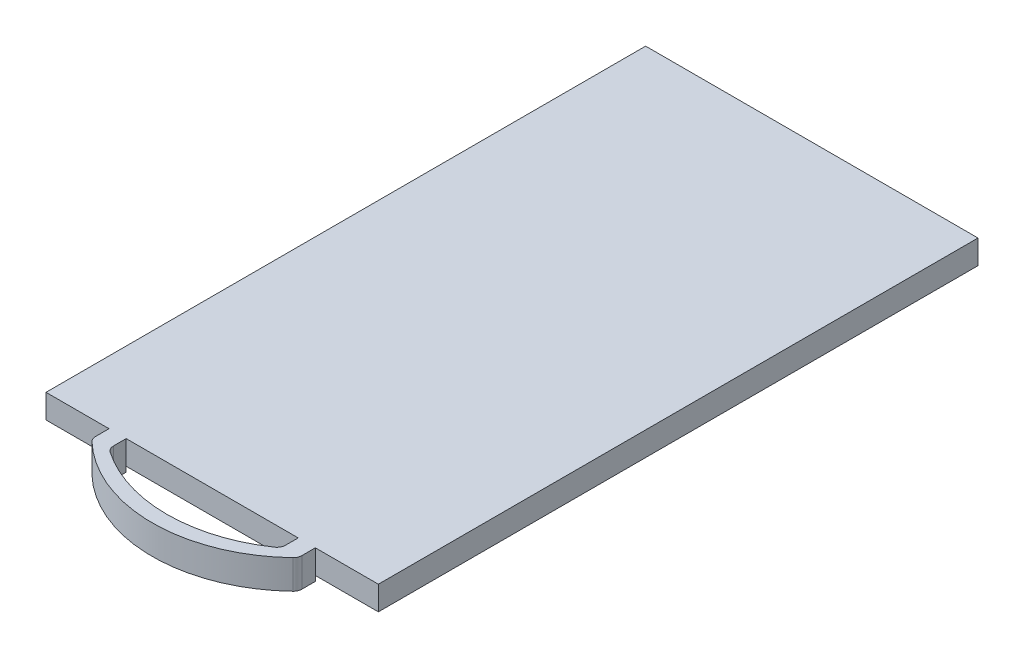
from build123d import *

# Parameters (mm, degrees)
SKETCH1_W           = 19.4
SKETCH1_H           = 1.4
BOSS_EXTRUDE1_DEPTH = 35
BOSS_EXTRUDE2_DEPTH = 1.7


with BuildPart() as part:
    # Sketch1 → Boss-Extrude1 (new body)
    with BuildSketch(Plane.XY):
        with Locations((9.7, 0.7)):
            Rectangle(SKETCH1_W, SKETCH1_H)
    extrude(amount=BOSS_EXTRUDE1_DEPTH)

    # Sketch3 → Boss-Extrude2 (add)
    with BuildSketch(Plane(origin=(0, 1.4, 0), x_dir=(1, 0, 0), z_dir=(0, 1, 0))):
        with BuildLine():
            Line((3.679202711, -35), (3.679202711, -35.789714785))
            ThreePointArc((3.679202711, -35.789714785), (3.719569751, -35.986533337), (3.83415288, -36.151571959))
            ThreePointArc((3.83415288, -36.151571959), (9.7, -38.5), (15.56584712, -36.151571959))
            ThreePointArc((15.56584712, -36.151571959), (15.680430249, -35.986533337), (15.720797289, -35.789714785))
            Line((15.720797289, -35.789714785), (15.720797289, -35))
            Line((15.720797289, -35), (14.720797289, -35))
            Line((14.720797289, -35), (14.720797289, -35.741493674))
            ThreePointArc((14.720797289, -35.741493674), (14.663106522, -35.974651436), (14.50334712, -36.154004999))
            ThreePointArc((14.50334712, -36.154004999), (9.7, -37.641312474), (4.89665288, -36.154004999))
            ThreePointArc((4.89665288, -36.154004999), (4.736893478, -35.974651436), (4.679202711, -35.741493674))
            Line((4.679202711, -35.741493674), (4.679202711, -35))
            Line((4.679202711, -35), (3.679202711, -35))
        make_face()
    extrude(amount=-BOSS_EXTRUDE2_DEPTH)


solid = part.part
